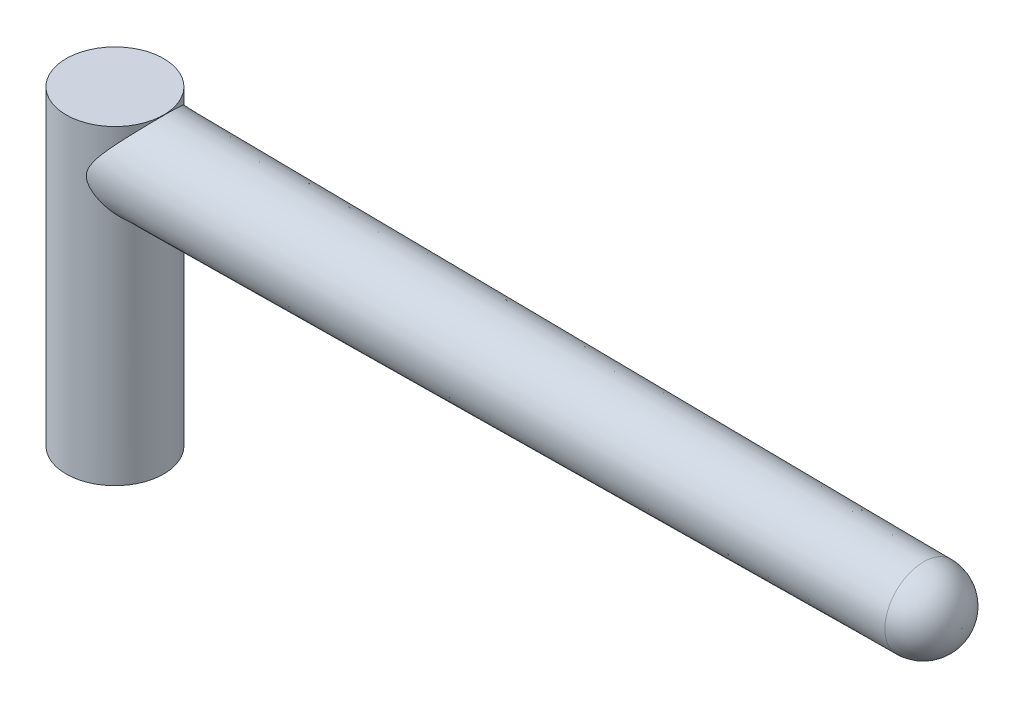
from build123d import *

# Parameters (mm, degrees)
SKETCH1_R           = 4.95
BOSS_EXTRUDE1_DEPTH = 31.55
SKETCH3_R           = 4.65
BOSS_EXTRUDE2_DEPTH = 85.9
BOSS_EXTRUDE2_TAPER = 0.5
FILLET1_R           = 3.9
SKETCH4_R           = 3.07
CUT_EXTRUDE1_DEPTH  = 5.3


with BuildPart() as part:
    # Sketch1 → Boss-Extrude1 (new body)
    with BuildSketch(Plane(origin=(0, 0, 0), x_dir=(1, 0, 0), z_dir=(0, 1, 0))):
        Circle(SKETCH1_R)
    extrude(amount=BOSS_EXTRUDE1_DEPTH)

    # Sketch3 → Boss-Extrude2 (add)
    with BuildSketch(Plane(origin=(0, 0, 0), x_dir=(0, 0, -1), z_dir=(1, 0, 0))):
        with Locations((0, 26.9)):
            Circle(SKETCH3_R)
    extrude(amount=BOSS_EXTRUDE2_DEPTH, taper=BOSS_EXTRUDE2_TAPER)

    # Fillet1
    fillet1_edges = [part.edges().sort_by_distance(p)[0] for p in [
        (85.9, 26.9, 3.900362057),
    ]]
    fillet(fillet1_edges, radius=FILLET1_R)

    # Sketch4 → Cut-Extrude1 (cut)
    with BuildSketch(Plane.XZ):
        Circle(SKETCH4_R)
    extrude(amount=-CUT_EXTRUDE1_DEPTH, mode=Mode.SUBTRACT)


solid = part.part
